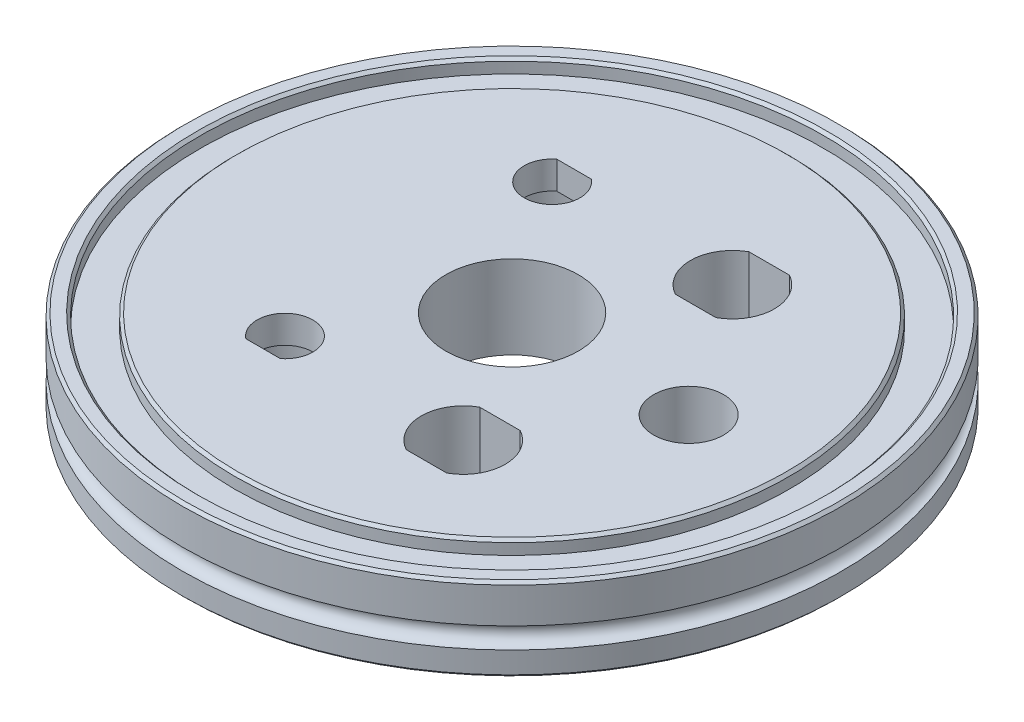
from build123d import *

# Parameters (mm, degrees)
SKETCH3_R          = 5.05
CUT_EXTRUDE1_DEPTH = 13
SKETCH6_R          = 6.95
CUT_EXTRUDE2_DEPTH = 8
SKETCH7_R          = 9.55
CUT_EXTRUDE3_DEPTH = 13


with BuildPart() as part:
    # Sketch1 → Revolve1 (revolve)
    with BuildSketch(Plane(origin=(0, 0, 0), x_dir=(-1, 0, 0), z_dir=(0, 0, -1))):
        with BuildLine():
            Line((-31.1, 0), (0, 0))
            Line((0, 0), (0, 12))
            Line((0, 12), (-39.6, 12))
            Line((-39.6, 12), (-40, 11.6))
            Line((-40, 11.6), (-40, 10))
            Line((-40, 10), (-45, 10))
            Line((-45, 10), (-45, 11.6))
            Line((-45, 11.6), (-45.4, 12))
            Line((-45.4, 12), (-47.1, 12))
            Line((-47.1, 12), (-47.5, 11.6))
            Line((-47.5, 11.6), (-47.5, 6.5))
            ThreePointArc((-47.5, 6.5), (-46, 5), (-47.5, 3.5))
            Line((-47.5, 3.5), (-47.5, 0.4))
            Line((-47.5, 0.4), (-47.1, 0))
            Line((-47.1, 0), (-35.4, 0))
            Line((-35.4, 0), (-35, 0.4))
            Line((-35, 0.4), (-35, 4.5))
            Line((-35, 4.5), (-31.5, 4.5))
            Line((-31.5, 4.5), (-31.5, 0.4))
            Line((-31.5, 0.4), (-31.1, 0))
        make_face()
    revolve(axis=Axis((0, 0, 0), (0, 1, 0)))

    # Sketch3 → Cut-Extrude1 (cut, through all)
    with BuildSketch(Plane(origin=(0, 12, 0), x_dir=(1, 0, 0), z_dir=(0, 1, 0))):
        with Locations((25.45, 0)):
            Circle(SKETCH3_R)
        with BuildLine():
            Line((-10.993169052, 22.409315756), (-15.964923457, 22.409315756))
            ThreePointArc((-15.964923457, 22.409315756), (-13.479046254, 15.230073041), (-10.993169052, 22.409315756))
        make_face()
        with BuildLine():
            Line((9.4402721, 24.698003254), (15.275509884, 24.698003254))
            ThreePointArc((15.275509884, 24.698003254), (18.407890992, 19.398003254), (15.275509884, 14.098003254))
            Line((15.275509884, 14.098003254), (9.4402721, 14.098003254))
            ThreePointArc((9.4402721, 14.098003254), (6.307890992, 19.398003254), (9.4402721, 24.698003254))
        make_face()
        with BuildLine():
            Line((-10.993169052, -22.409315756), (-15.964923457, -22.409315756))
            ThreePointArc((-15.964923457, -22.409315756), (-13.479046254, -15.230073041), (-10.993169052, -22.409315756))
        make_face()
        with BuildLine():
            Line((9.4402721, -14.098003254), (15.275509884, -14.098003254))
            ThreePointArc((15.275509884, -14.098003254), (18.407890992, -19.398003254), (15.275509884, -24.698003254))
            Line((15.275509884, -24.698003254), (9.4402721, -24.698003254))
            ThreePointArc((9.4402721, -24.698003254), (6.307890992, -19.398003254), (9.4402721, -14.098003254))
        make_face()
    extrude(amount=-CUT_EXTRUDE1_DEPTH, mode=Mode.SUBTRACT)

    # Sketch6 → Cut-Extrude2 (cut)
    with BuildSketch(Plane(origin=(0, 0, 0), x_dir=(-1, 0, 0), z_dir=(0, -1, 0))):
        with Locations((13.479046254, 19.250073041)):
            Circle(SKETCH6_R)
        with Locations((13.479046254, -19.250073041)):
            Circle(SKETCH6_R)
    extrude(amount=-CUT_EXTRUDE2_DEPTH, mode=Mode.SUBTRACT)

    # Sketch7 → Cut-Extrude3 (cut, through all)
    with BuildSketch(Plane(origin=(0, 12, 0), x_dir=(1, 0, 0), z_dir=(0, 1, 0))):
        Circle(SKETCH7_R)
    extrude(amount=-CUT_EXTRUDE3_DEPTH, mode=Mode.SUBTRACT)


solid = part.part
